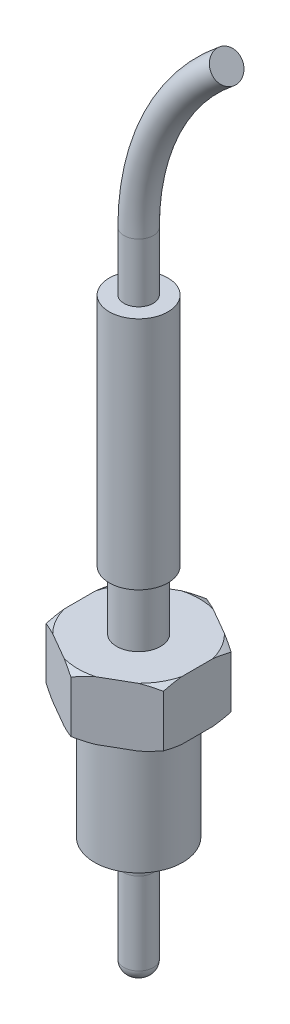
from build123d import *

# Parameters (mm, degrees)
SKETCH2_OUTSIDE_W  = 41.992
SKETCH2_OUTSIDE_H  = 41.992
CUT_EXTRUDE1_DEPTH = 64.5
FILLET1_R          = 2.54
FILLET2_R          = 1.27
SWEEP1_PROFILE_R   = 1.5875


with BuildPart() as part:
    # Sketch1 → Revolve1 (revolve)
    with BuildSketch(Plane.XY):
        Polygon((0, 0), (0, 63.5), (3.175, 63.5), (3.175, 38.1), (2.38125, 38.1), (2.38125, 31.75), (12.7, 31.75), (12.7, 25.4), (4.7625, 25.4), (4.7625, 12.7), (1.5875, 12.7), (1.5875, 0), align=None)
    revolve(axis=Axis((0, 0, 0), (0, -1, 0)))

    # Sketch2 outside → Cut-Extrude1 (cut, through all)
    with BuildSketch(Plane(origin=(0, 0, 0), x_dir=(1, 0, 0), z_dir=(0, 1, 0))):
        Rectangle(SKETCH2_OUTSIDE_W, SKETCH2_OUTSIDE_H)
        Polygon((6.35, 3.666174209), (0, 7.332348419), (-6.35, 3.666174209), (-6.35, -3.666174209), (0, -7.332348419), (6.35, -3.666174209), align=None, mode=Mode.SUBTRACT)
    extrude(amount=CUT_EXTRUDE1_DEPTH, mode=Mode.SUBTRACT)

    # Sketch3 → Cut-Revolve1 (revolve, cut)
    with BuildSketch(Plane(origin=(0, 0, 0), x_dir=(0, 0, -1), z_dir=(1, 0, 0))):
        with BuildLine():
            Line((7.332348419, 31.369), (7.332348419, 25.781))
            ThreePointArc((7.332348419, 25.781), (6.9545441, 25.584108638), (6.570348419, 25.4))
            ThreePointArc((6.570348419, 25.4), (12.560590782, 25.250588883), (17.545931088, 28.575))
            ThreePointArc((17.545931088, 28.575), (12.560590782, 31.899411117), (6.570348419, 31.75))
            ThreePointArc((6.570348419, 31.75), (6.9545441, 31.565891362), (7.332348419, 31.369))
        make_face()
    revolve(axis=Axis((0, 0, 0), (0, 1, 0)), mode=Mode.SUBTRACT)

    # Fillet1
    fillet1_edges = [part.edges().sort_by_distance(p)[0] for p in [
        (-1.5875, 12.7, 0),
    ]]
    fillet(fillet1_edges, radius=FILLET1_R)

    # Fillet2
    fillet2_edges = [part.edges().sort_by_distance(p)[0] for p in [
        (-1.5875, 0, 0),
    ]]
    fillet(fillet2_edges, radius=FILLET2_R)

    # Sweep1: sweep along a path in Sketch4
    with BuildLine(Plane.XY) as sweep1_path:
        Line((0, 63.5), (0, 69.85))
        ThreePointArc((0, 69.85), (2.504749401, 80.848522628), (9.525, 89.677868645))
    # Sweep1 profile (on start of the path) → Sweep1 (sweep)
    with BuildSketch(Plane.ZX.offset(63.5)):
        Circle(SWEEP1_PROFILE_R)
    sweep(path=sweep1_path.line)


solid = part.part
